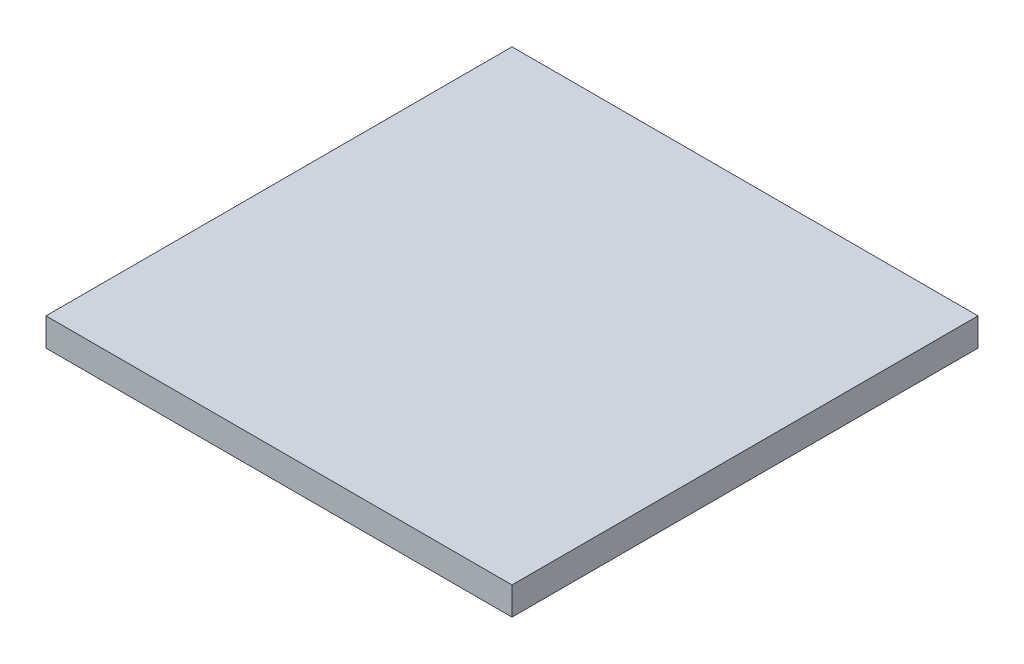
from build123d import *

# Parameters (mm, degrees)
SKETCH_1_W      = 50
SKETCH_1_H      = 50
EXTRUDE_1_DEPTH = 3


with BuildPart() as part:
    # 草图1 → 凸台-拉伸1 (new body)
    with BuildSketch(Plane(origin=(0, 0, 0), x_dir=(1, 0, 0), z_dir=(0, 1, 0))):
        Rectangle(SKETCH_1_W, SKETCH_1_H)
    extrude(amount=EXTRUDE_1_DEPTH)


solid = part.part
